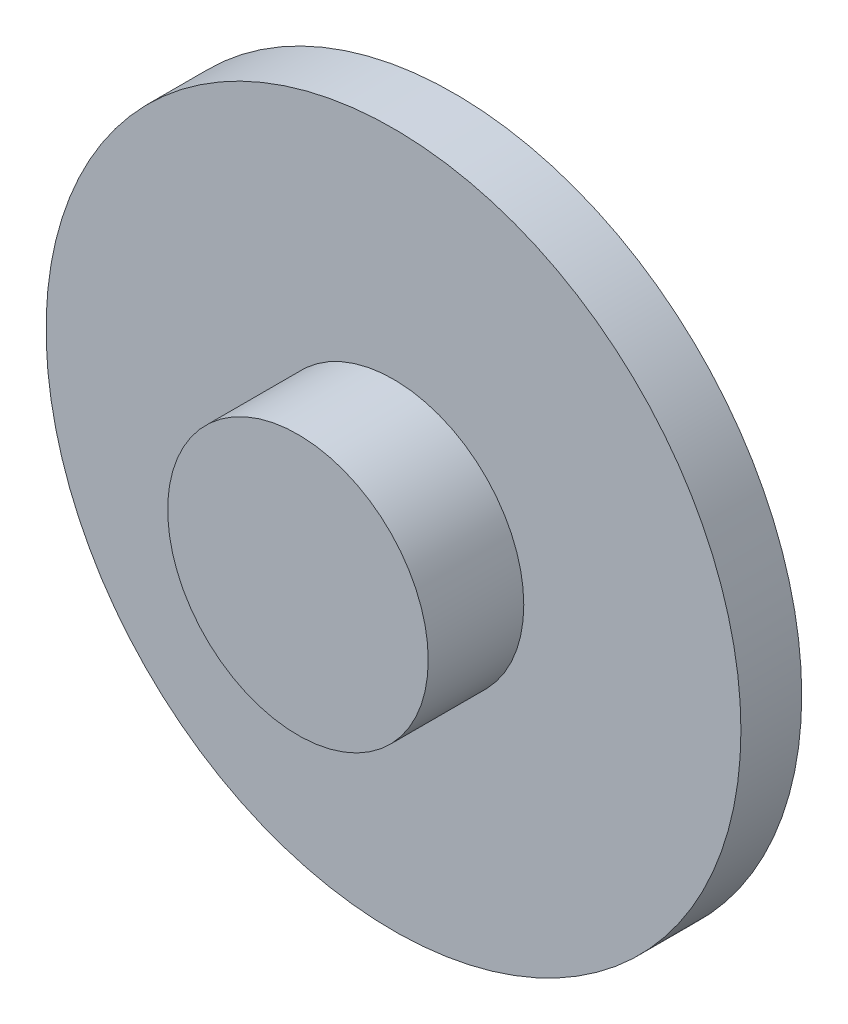
from build123d import *

# Parameters (mm, degrees)
SKETCH2_R           = 10.16
SKETCH2_R_2         = 3.81
BOSS_EXTRUDE1_DEPTH = 1.778
SKETCH2_3_R         = 10.16
SKETCH2_3_R_2       = 3.81
BOSS_EXTRUDE2_DEPTH = 1.778
SKETCH2_4_R         = 3.81
BOSS_EXTRUDE3_DEPTH = 4.572


with BuildPart() as part:
    # Sketch2 → Boss-Extrude1 (new body)
    with BuildSketch(Plane.XY):
        Circle(SKETCH2_R)
        Circle(SKETCH2_R_2, mode=Mode.SUBTRACT)
    extrude(amount=BOSS_EXTRUDE1_DEPTH)

    # Sketch2_3 → Boss-Extrude2 (add)
    with BuildSketch(Plane.XY):
        Circle(SKETCH2_3_R)
        Circle(SKETCH2_3_R_2, mode=Mode.SUBTRACT)
    extrude(amount=BOSS_EXTRUDE2_DEPTH)

    # Sketch2_4 → Boss-Extrude3 (add)
    with BuildSketch(Plane.XY):
        Circle(SKETCH2_4_R)
    extrude(amount=BOSS_EXTRUDE3_DEPTH)


solid = part.part
